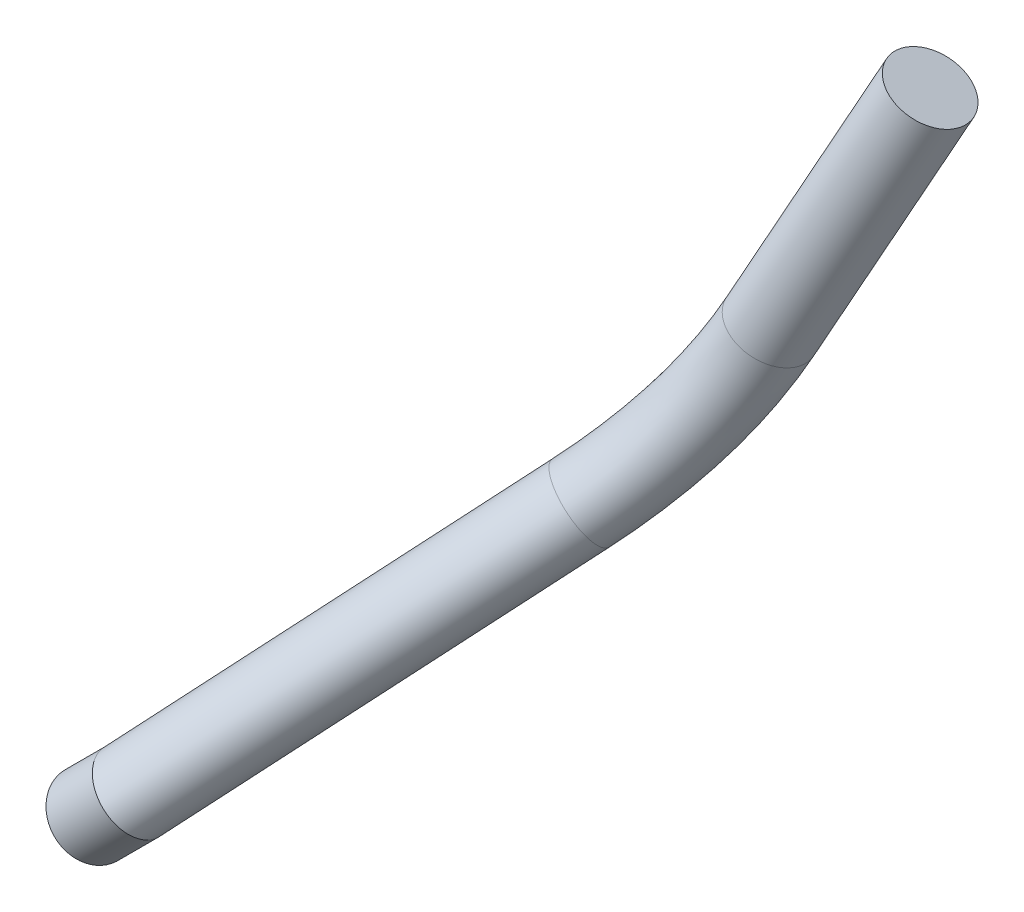
from build123d import *

# Parameters (mm, degrees)
SWEEP1_PROFILE_R = 4.699


with BuildPart() as part:
    # Sweep1: sweep along a curve in space
    with BuildLine() as sweep1_path:
        Line((238.754370819, 134.269695833, 168.702443465), (253.620262853, 165.140017683, 163.321796801))
        ThreePointArc((225.215214035, 113.368458468, 179.112833538), (232.362452735, 122.832817986, 172.418661174), (238.754370819, 134.269695833, 168.702443465))
        Line((198.085125282, 82.991088831, 208.7608), (225.215214035, 113.368458468, 179.112833538))
        Line((198.085125282, 82.991088831, 208.7608), (193.010891229, 77.916854778, 208.7608))
    # Sweep1 profile (on start of the path) → Sweep1 (sweep)
    with BuildSketch(Plane(origin=(193.010891229, 77.916854778, 208.7608), x_dir=(-0.707106781, 0.707106781, 0), z_dir=(0.707106781, 0.707106781, 0))):
        Circle(SWEEP1_PROFILE_R)
    sweep(path=sweep1_path.line, transition=Transition.RIGHT)


solid = part.part
